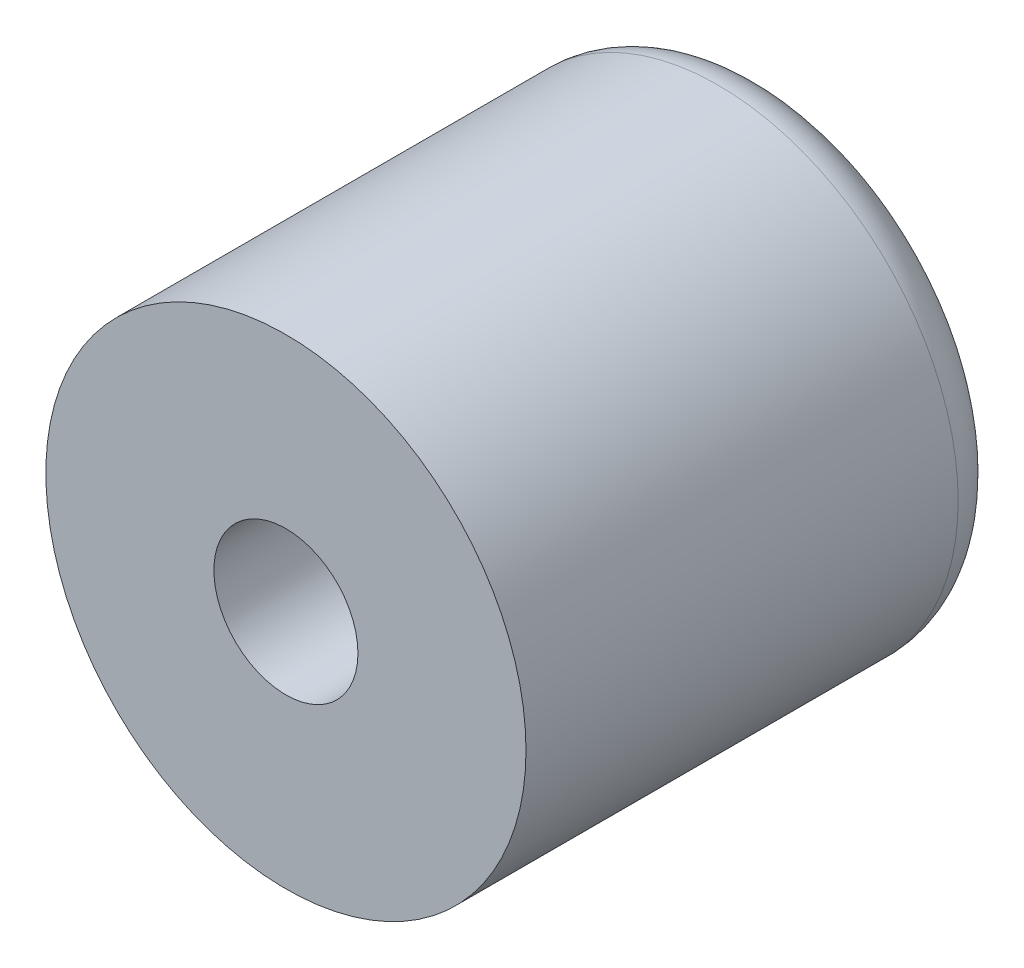
from build123d import *

# Parameters (mm, degrees)
ESQUISSE1_R             = 5
BOSS_EXTRU_1_DEPTH      = 10
ESQUISSE2_R             = 1.5
ENL_V_MAT_EXTRU_1_DEPTH = 7
ESQUISSE3_R             = 1
ENL_V_MAT_EXTRU_2_DEPTH = 7
CONG_1_R                = 1


with BuildPart() as part:
    # Esquisse1 → Boss.-Extru.1 (new body)
    with BuildSketch(Plane.XY):
        Circle(ESQUISSE1_R)
    extrude(amount=BOSS_EXTRU_1_DEPTH)

    # Esquisse2 → Enlèv. mat.-Extru.1 (cut)
    with BuildSketch(Plane.XY.offset(10)):
        Circle(ESQUISSE2_R)
    extrude(amount=-ENL_V_MAT_EXTRU_1_DEPTH, mode=Mode.SUBTRACT)

    # Esquisse3 → Enlèv. mat.-Extru.2 (cut)
    with BuildSketch(Plane.XY.offset(3)):
        Circle(ESQUISSE3_R)
    extrude(amount=-ENL_V_MAT_EXTRU_2_DEPTH, mode=Mode.SUBTRACT)

    # Congé1
    cong_1_edges = [part.edges().sort_by_distance(p)[0] for p in [
        (-5, 0, 0),
    ]]
    fillet(cong_1_edges, radius=CONG_1_R)


solid = part.part
